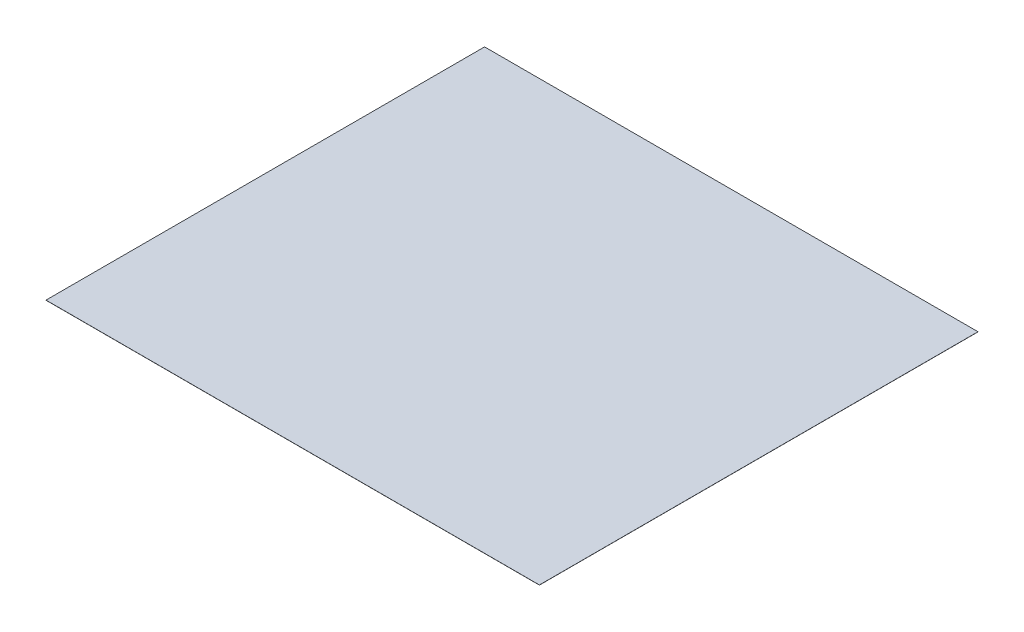
from build123d import *

# Parameters (mm, degrees)
SKETCH1_W           = 5486.4
SKETCH1_H           = 4876.8
BOSS_EXTRUDE1_DEPTH = 1.5875


with BuildPart() as part:
    # Sketch1 → Boss-Extrude1 (new body)
    with BuildSketch(Plane(origin=(0, 0, 0), x_dir=(1, 0, 0), z_dir=(0, 1, 0))):
        Rectangle(SKETCH1_W, SKETCH1_H)
    extrude(amount=BOSS_EXTRUDE1_DEPTH)


solid = part.part
